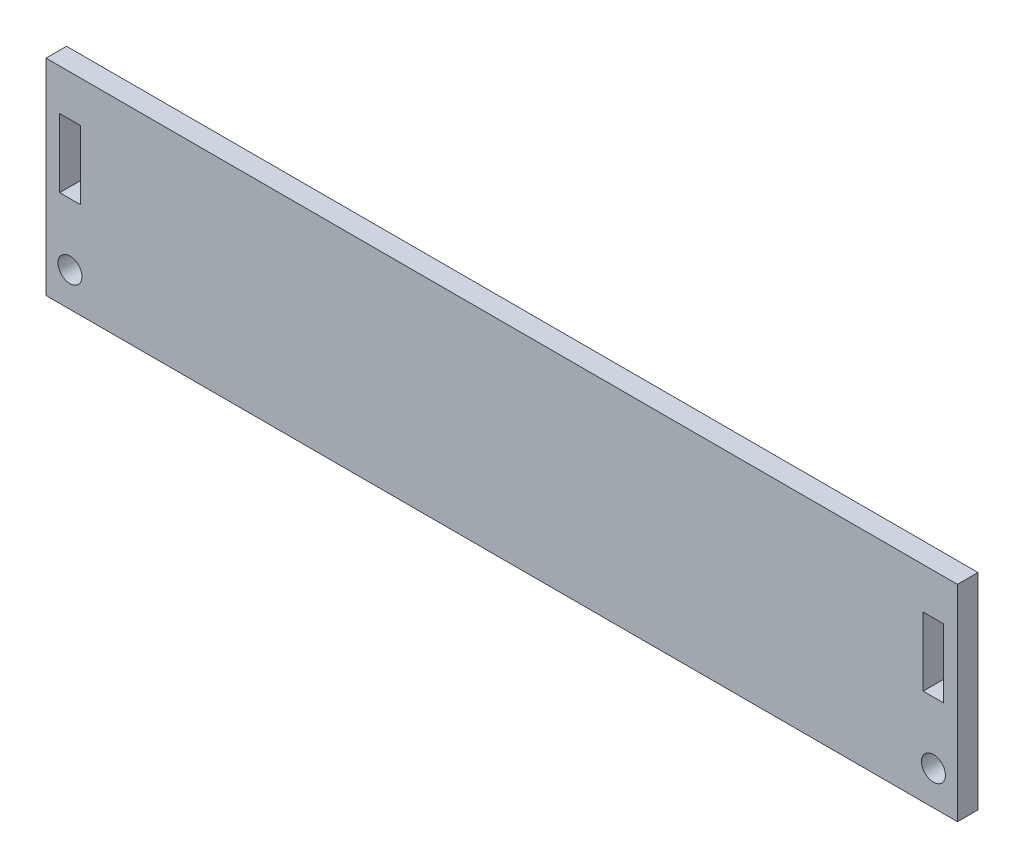
from build123d import *

# Parameters (mm, degrees)
SKETCH1_W           = 133
SKETCH1_H           = 30
SKETCH1_R           = 1.75
SKETCH1_W_2         = 3
SKETCH1_H_2         = 10
BOSS_EXTRUDE1_DEPTH = 3


with BuildPart() as part:
    # Sketch1 → Boss-Extrude1 (new body)
    with BuildSketch(Plane.XY):
        with Locations((0, 2.5)):
            Rectangle(SKETCH1_W, SKETCH1_H)
        with Locations((-63, -7.5)):
            Circle(SKETCH1_R, mode=Mode.SUBTRACT)
        with Locations((63, -7.5)):
            Circle(SKETCH1_R, mode=Mode.SUBTRACT)
        with Locations((63, 6.5)):
            Rectangle(SKETCH1_W_2, SKETCH1_H_2, mode=Mode.SUBTRACT)
        with Locations((-63, 6.5)):
            Rectangle(SKETCH1_W_2, SKETCH1_H_2, mode=Mode.SUBTRACT)
    extrude(amount=BOSS_EXTRUDE1_DEPTH)


solid = part.part
